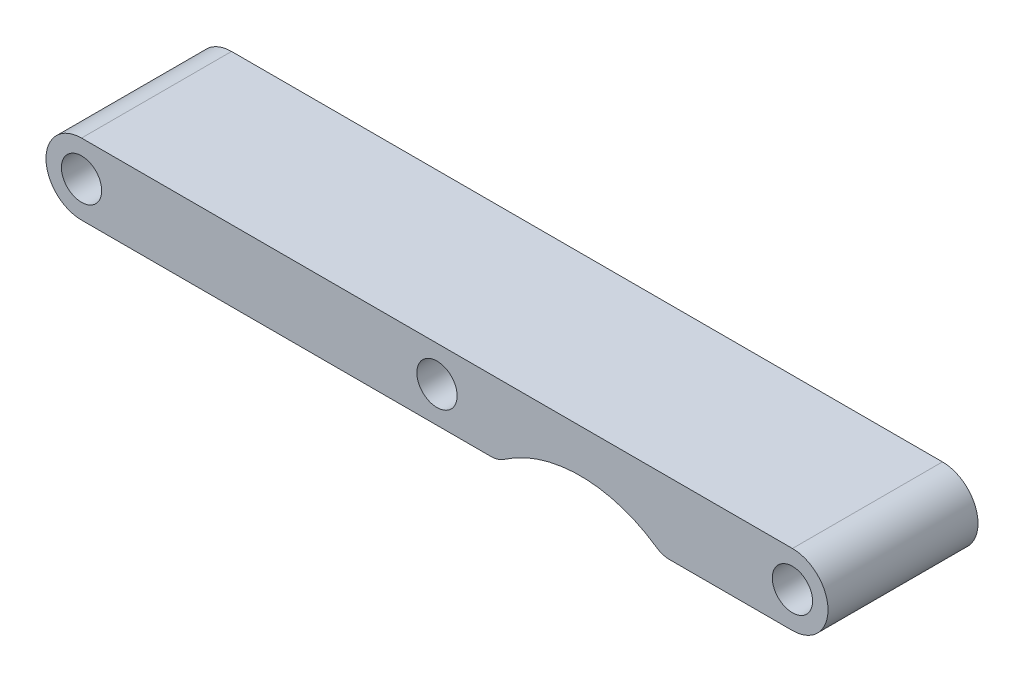
from build123d import *

# Parameters (mm, degrees)
SKETCH1_R           = 2.159
BOSS_EXTRUDE1_DEPTH = 16.0782
FILLET1_R           = 2.54


with BuildPart() as part:
    # Sketch1 → Boss-Extrude1 (new body)
    with BuildSketch(Plane.XY):
        with BuildLine():
            Line((0, 7.62), (76.2, 7.62))
            ThreePointArc((76.2, 7.62), (80.01, 3.81), (76.2, 0))
            Line((76.2, 0), (62.219445877, 0))
            ThreePointArc((62.219445877, 0), (53.46050014, 2.99974), (44.701554403, 0))
            Line((44.701554403, 0), (0, 0))
            ThreePointArc((0, 0), (-3.81, 3.81), (0, 7.62))
        make_face()
        with Locations((0, 3.81)):
            Circle(SKETCH1_R, mode=Mode.SUBTRACT)
        with Locations((38.1, 3.81)):
            Circle(SKETCH1_R, mode=Mode.SUBTRACT)
        with Locations((76.2, 3.81)):
            Circle(SKETCH1_R, mode=Mode.SUBTRACT)
    extrude(amount=BOSS_EXTRUDE1_DEPTH)

    # Fillet1
    fillet1_edges = [part.edges().sort_by_distance(p)[0] for p in [
        (62.219445877, 0, 8.0391),
        (44.701554403, 0, 8.0391),
    ]]
    fillet(fillet1_edges, radius=FILLET1_R)


solid = part.part
